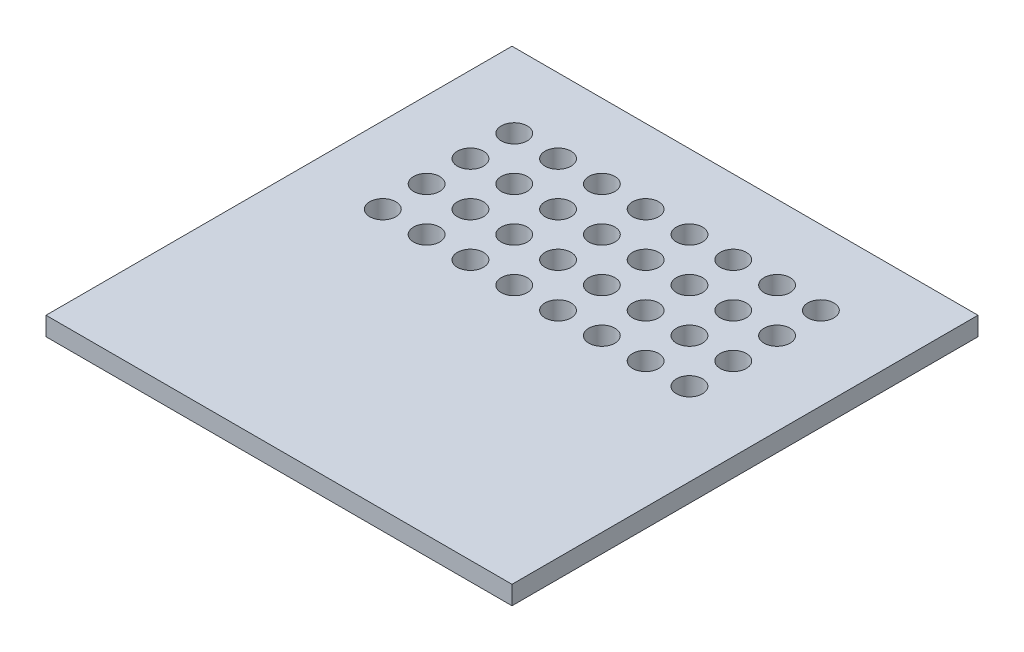
from build123d import *

# Parameters (mm, degrees)
SKETCH1_W           = 25
SKETCH1_H           = 25
SKETCH1_R           = 0.7
BOSS_EXTRUDE1_DEPTH = 1


with BuildPart() as part:
    # Sketch1 → Boss-Extrude1 (new body)
    with BuildSketch(Plane(origin=(0, 0, 0), x_dir=(1, 0, 0), z_dir=(0, 1, 0))):
        Rectangle(SKETCH1_W, SKETCH1_H)
        with Locations((-8.39, 8.51)):
            Circle(SKETCH1_R, mode=Mode.SUBTRACT)
        with Locations((-6.04, 8.51)):
            Circle(SKETCH1_R, mode=Mode.SUBTRACT)
        with Locations((-3.69, 8.51)):
            Circle(SKETCH1_R, mode=Mode.SUBTRACT)
        with Locations((-1.34, 8.51)):
            Circle(SKETCH1_R, mode=Mode.SUBTRACT)
        with Locations((1.01, 8.51)):
            Circle(SKETCH1_R, mode=Mode.SUBTRACT)
        with Locations((3.36, 8.51)):
            Circle(SKETCH1_R, mode=Mode.SUBTRACT)
        with Locations((5.71, 8.51)):
            Circle(SKETCH1_R, mode=Mode.SUBTRACT)
        with Locations((8.06, 8.51)):
            Circle(SKETCH1_R, mode=Mode.SUBTRACT)
        with Locations((-6.04, 6.16)):
            Circle(SKETCH1_R, mode=Mode.SUBTRACT)
        with Locations((-3.69, 6.16)):
            Circle(SKETCH1_R, mode=Mode.SUBTRACT)
        with Locations((-1.34, 6.16)):
            Circle(SKETCH1_R, mode=Mode.SUBTRACT)
        with Locations((1.01, 6.16)):
            Circle(SKETCH1_R, mode=Mode.SUBTRACT)
        with Locations((3.36, 6.16)):
            Circle(SKETCH1_R, mode=Mode.SUBTRACT)
        with Locations((5.71, 6.16)):
            Circle(SKETCH1_R, mode=Mode.SUBTRACT)
        with Locations((8.06, 6.16)):
            Circle(SKETCH1_R, mode=Mode.SUBTRACT)
        with Locations((-6.04, 3.81)):
            Circle(SKETCH1_R, mode=Mode.SUBTRACT)
        with Locations((-3.69, 3.81)):
            Circle(SKETCH1_R, mode=Mode.SUBTRACT)
        with Locations((-1.34, 3.81)):
            Circle(SKETCH1_R, mode=Mode.SUBTRACT)
        with Locations((1.01, 3.81)):
            Circle(SKETCH1_R, mode=Mode.SUBTRACT)
        with Locations((3.36, 3.81)):
            Circle(SKETCH1_R, mode=Mode.SUBTRACT)
        with Locations((5.71, 3.81)):
            Circle(SKETCH1_R, mode=Mode.SUBTRACT)
        with Locations((8.06, 3.81)):
            Circle(SKETCH1_R, mode=Mode.SUBTRACT)
        with Locations((-6.04, 1.46)):
            Circle(SKETCH1_R, mode=Mode.SUBTRACT)
        with Locations((-3.69, 1.46)):
            Circle(SKETCH1_R, mode=Mode.SUBTRACT)
        with Locations((-1.34, 1.46)):
            Circle(SKETCH1_R, mode=Mode.SUBTRACT)
        with Locations((1.01, 1.46)):
            Circle(SKETCH1_R, mode=Mode.SUBTRACT)
        with Locations((3.36, 1.46)):
            Circle(SKETCH1_R, mode=Mode.SUBTRACT)
        with Locations((5.71, 1.46)):
            Circle(SKETCH1_R, mode=Mode.SUBTRACT)
        with Locations((8.06, 1.46)):
            Circle(SKETCH1_R, mode=Mode.SUBTRACT)
        with Locations((-8.39, 6.16)):
            Circle(SKETCH1_R, mode=Mode.SUBTRACT)
        with Locations((-8.39, 3.81)):
            Circle(SKETCH1_R, mode=Mode.SUBTRACT)
        with Locations((-8.39, 1.46)):
            Circle(SKETCH1_R, mode=Mode.SUBTRACT)
    extrude(amount=BOSS_EXTRUDE1_DEPTH)


solid = part.part
